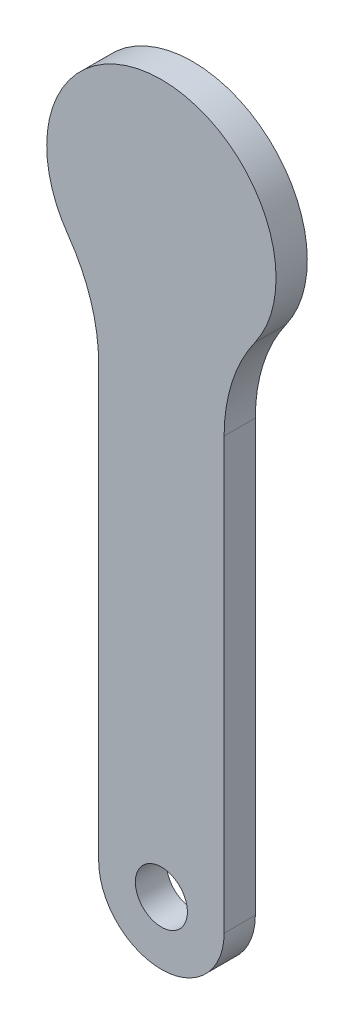
from build123d import *

# Parameters (mm, degrees)
SKETCH1_R           = 2.5
BOSS_EXTRUDE1_DEPTH = 3


with BuildPart() as part:
    # Sketch1 → Boss-Extrude1 (new body)
    with BuildSketch(Plane.XY):
        with BuildLine():
            Line((6.025139131, -15.636232903), (6.025139131, -57))
            ThreePointArc((6.025139131, -57), (4.260416737, -61.260416737), (0, -63.025139131))
            ThreePointArc((0, -63.025139131), (-4.260416737, -61.260416737), (-6.025139131, -57))
            Line((-6.025139131, -57), (-6.025139131, -15.636232903))
            ThreePointArc((-6.025139131, -15.636232903), (-6.781462516, -10.778273635), (-8.978839155, -6.380168449))
            ThreePointArc((-8.978839155, -6.380168449), (0, 11.014812844), (8.978839155, -6.380168449))
            ThreePointArc((8.978839155, -6.380168449), (6.781462516, -10.778273635), (6.025139131, -15.636232903))
        make_face()
        with Locations((0, -57)):
            Circle(SKETCH1_R, mode=Mode.SUBTRACT)
    extrude(amount=BOSS_EXTRUDE1_DEPTH)


solid = part.part
